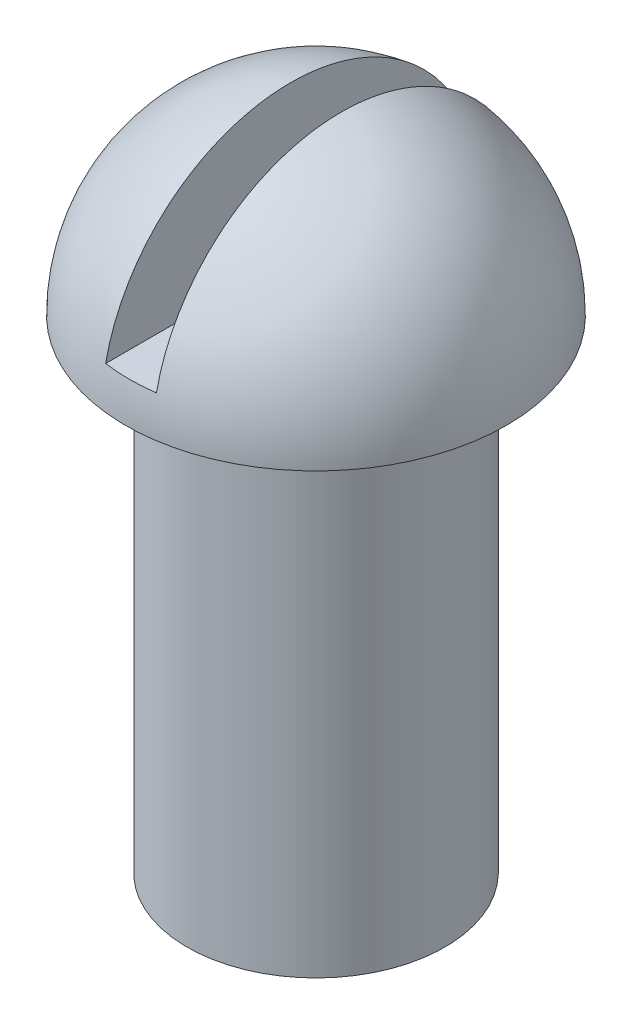
from build123d import *

# Parameters (mm, degrees)
SKETCH2_W               = 4
SKETCH2_H               = 20.325154634
CUT_EXTRUDE1_DEPTH      = 16
CUT_EXTRUDE1_DEPTH_BACK = 16


with BuildPart() as part:
    # Sketch1 → Revolve1 (revolve)
    with BuildSketch(Plane.XY):
        with BuildLine():
            Line((0, 53), (0, 0))
            Line((0, 0), (10.15, 0))
            Line((10.15, 0), (10.15, 38))
            Line((10.15, 38), (15, 38))
            ThreePointArc((15, 38), (10.606601718, 48.606601718), (0, 53))
        make_face()
    revolve(axis=Axis((0, 53, 0), (0, -1, 0)))

    # Sketch2 → Cut-Extrude1 (cut, two sides)
    with BuildSketch(Plane.XY) as cut_extrude1_sk:
        with Locations((0, 51.162577317)):
            Rectangle(SKETCH2_W, SKETCH2_H)
    extrude(amount=CUT_EXTRUDE1_DEPTH, mode=Mode.SUBTRACT)
    extrude(cut_extrude1_sk.sketch, amount=-CUT_EXTRUDE1_DEPTH_BACK, mode=Mode.SUBTRACT)


solid = part.part
